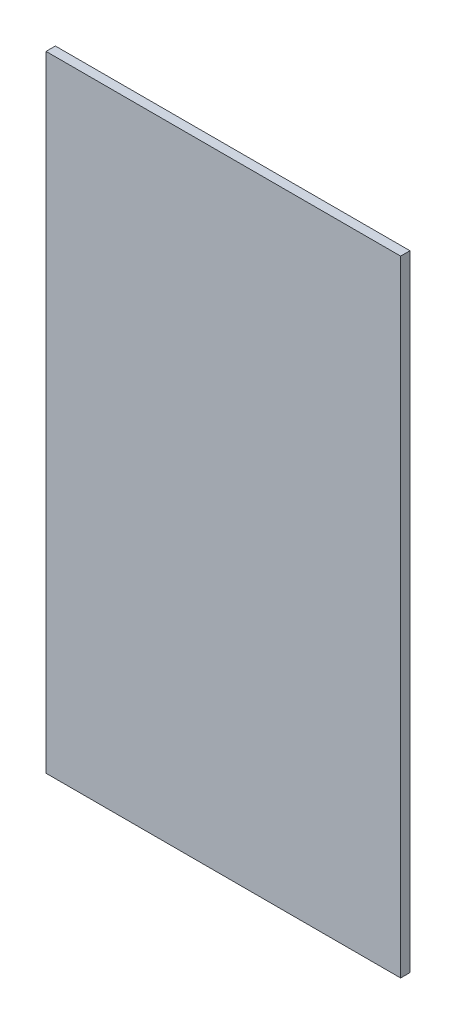
from build123d import *

# Parameters (mm, degrees)
ESQUISSE1_W        = 380
ESQUISSE1_H        = 670
BOSS_EXTRU_1_DEPTH = 10


with BuildPart() as part:
    # Esquisse1 → Boss.-Extru.1 (new body)
    with BuildSketch(Plane.XY):
        Rectangle(ESQUISSE1_W, ESQUISSE1_H)
    extrude(amount=BOSS_EXTRU_1_DEPTH)


solid = part.part
